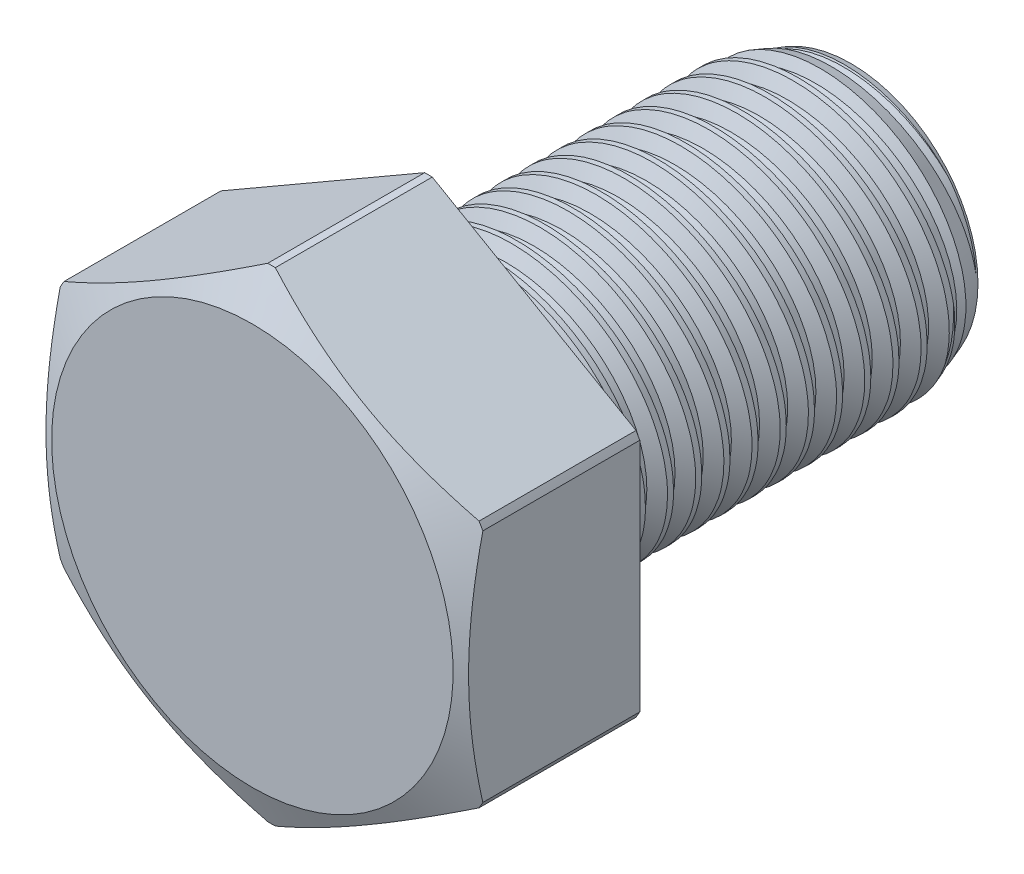
from build123d import *

# Parameters (mm, degrees)
SKETCH1_W       = 19.05
SKETCH1_H       = 6.35
LPATTERN1_COUNT = 15
LPATTERN1_PITCH = 1.27
LPATTERN2_COUNT = 2
LPATTERN2_PITCH = 1.27
EXTRUDE1_DEPTH  = 7.9375


with BuildPart() as part:
    # Sketch1 → Revolve1 (revolve)
    with BuildSketch(Plane(origin=(0, 0, 0), x_dir=(0, 0, -1), z_dir=(1, 0, 0)), mode=Mode.PRIVATE) as revolve1_sk:
        with Locations((9.525, 3.175)):
            Rectangle(SKETCH1_W, SKETCH1_H)
    revolve(revolve1_sk.sketch.rotate(Axis((0, 0, 0), (0, 0, 1)), 144.105088917), axis=Axis((0, 0, 0), (0, 0, 1)))

    # Sketch2 → Cut-Revolve1 (revolve, cut)
    with BuildSketch(Plane(origin=(0, 0, 0), x_dir=(0, 0, -1), z_dir=(1, 0, 0)), mode=Mode.PRIVATE) as cut_revolve1_sk:
        Polygon((0.157962154, 6.365796215), (1.263697232, 6.476369723), (0.937191466, 5.752882994), (0.621267158, 5.721290563), align=None)
    cut_revolve1 = revolve(cut_revolve1_sk.sketch.rotate(Axis((0, -0.135293799, 0), (0, 0.09950371902099917, -0.9950371902099892)), 180), axis=Axis((0, -0.135293799, 0), (0, 0.09950371902099917, -0.9950371902099892)), mode=Mode.SUBTRACT)

    # Sketch3 → Cut-Revolve2 (revolve, cut)
    with BuildSketch(Plane(origin=(0, 0, 0), x_dir=(0, 0, -1), z_dir=(1, 0, 0)), mode=Mode.PRIVATE) as cut_revolve2_sk:
        Polygon((19.05, 5.721290563), (17.322635019, 6.35), (19.05, 6.35), align=None)
    revolve(cut_revolve2_sk.sketch.rotate(Axis((0, 0, -17.322635019), (0, 0, 1)), 144.105088917), axis=Axis((0, 0, -17.322635019), (0, 0, 1)), mode=Mode.SUBTRACT)

    # LPattern1: Cut-Revolve1 ×15
    with Locations(*[(0, 0, -i * LPATTERN1_PITCH) for i in range(1, LPATTERN1_COUNT)]):
        add(cut_revolve1, mode=Mode.SUBTRACT)

    # LPattern2: Cut-Revolve1 ×2
    with Locations(*[(0, 0, i * LPATTERN2_PITCH) for i in range(1, LPATTERN2_COUNT)]):
        add(cut_revolve1, mode=Mode.SUBTRACT)

    # Sketch4 → Extrude1 (add)
    with BuildSketch(Plane.XY):
        Polygon((0, 10.998522628), (-9.525, 5.499261314), (-9.525, -5.499261314), (0, -10.998522628), (9.525, -5.499261314), (9.525, 5.499261314), align=None)
    extrude(amount=EXTRUDE1_DEPTH)

    # Sketch9 → Cut-Revolve3 (revolve, cut)
    with BuildSketch(Plane(origin=(0, 0, 0), x_dir=(0, 0, -1), z_dir=(1, 0, 0)), mode=Mode.PRIVATE) as cut_revolve3_sk:
        Polygon((-7.9375, 9.04875), (-7.073765787, 10.901033997), (0, 10.901033997), (0, 10.998522628), (-7.9375, 10.998522628), align=None)
    revolve(cut_revolve3_sk.sketch.rotate(Axis((0, 0, 0), (0, 0, 1)), 25.938969777), axis=Axis((0, 0, 0), (0, 0, 1)), mode=Mode.SUBTRACT)


solid = part.part
